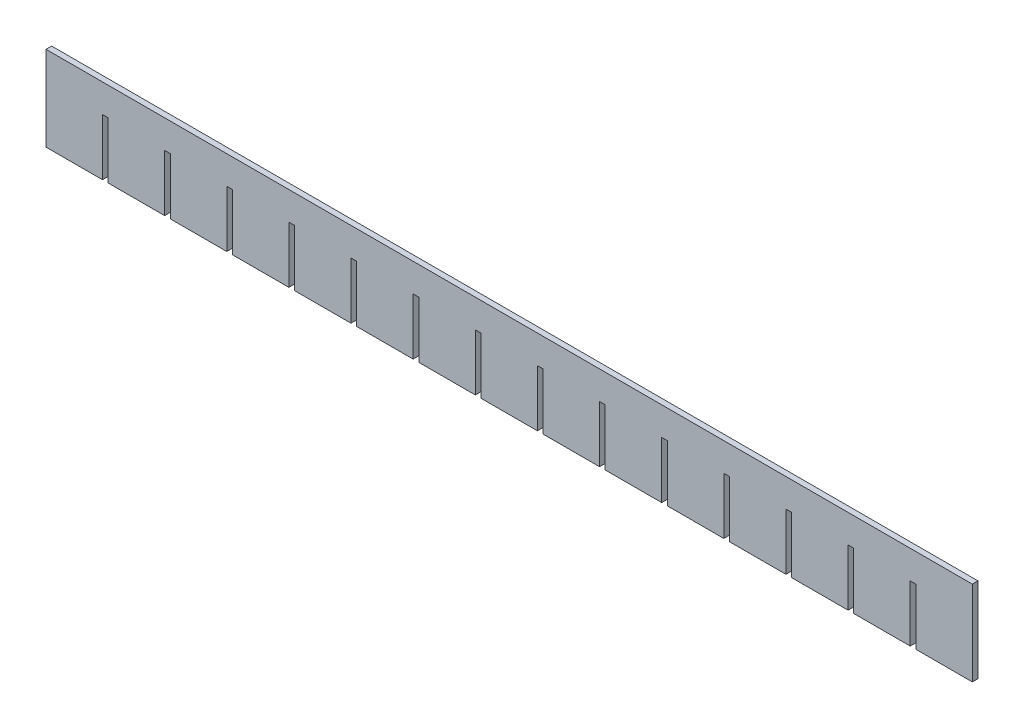
from build123d import *

# Parameters (mm, degrees)
SKETCH1_W           = 492
SKETCH1_H           = 45
BOSS_EXTRUDE1_DEPTH = 3
SKETCH2_W           = 3
SKETCH2_H           = 30
CUT_EXTRUDE1_DEPTH  = 4
LPATTERN1_COUNT     = 14
LPATTERN1_PITCH     = 33


with BuildPart() as part:
    # Sketch1 → Boss-Extrude1 (new body)
    with BuildSketch(Plane.XY):
        Rectangle(SKETCH1_W, SKETCH1_H)
    extrude(amount=BOSS_EXTRUDE1_DEPTH)

    # Sketch2 → Cut-Extrude1 (cut, through all)
    with BuildSketch(Plane.XY.offset(3)):
        with Locations((-214.5, -7.5)):
            Rectangle(SKETCH2_W, SKETCH2_H)
    cut_extrude1 = extrude(amount=-CUT_EXTRUDE1_DEPTH, mode=Mode.SUBTRACT)

    # LPattern1: Cut-Extrude1 ×14
    with Locations(*[(i * LPATTERN1_PITCH, 0, 0) for i in range(1, LPATTERN1_COUNT)]):
        add(cut_extrude1, mode=Mode.SUBTRACT)


solid = part.part
